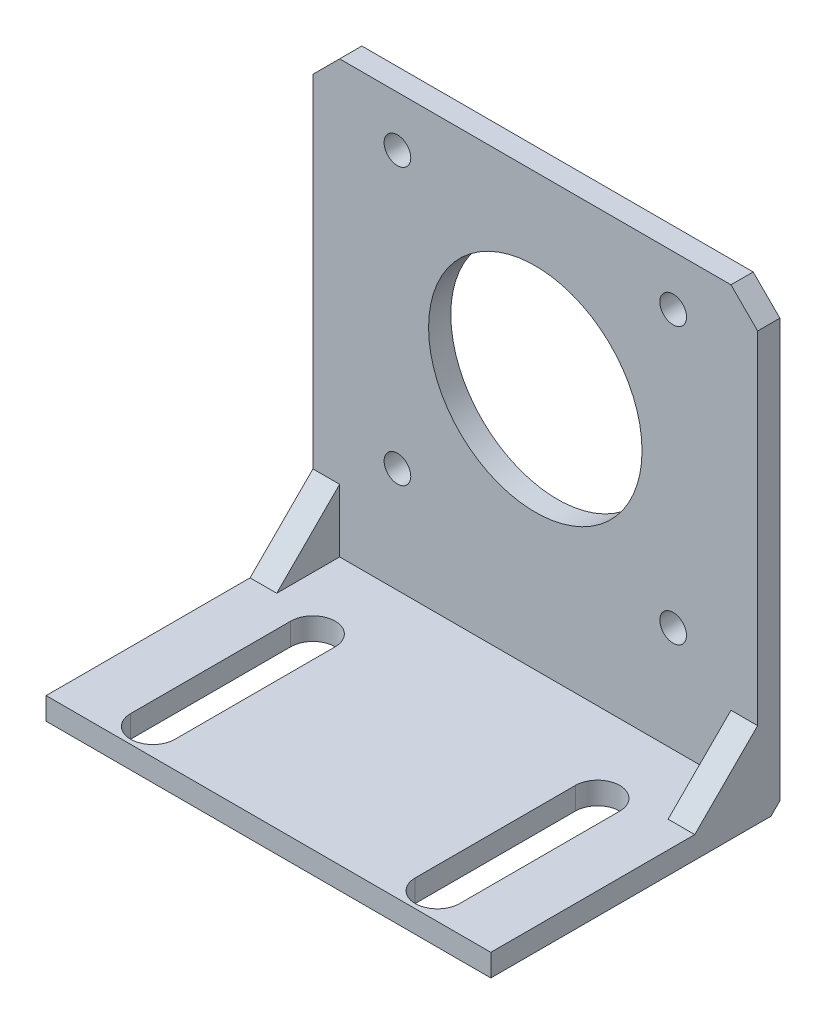
from build123d import *

# Parameters (mm, degrees)
SKETCH1_R           = 12
SKETCH1_R_2         = 1.5
BOSS_EXTRUDE1_DEPTH = 2.5
BOSS_EXTRUDE2_DEPTH = 2.5
SKETCH3_W           = 50
SKETCH3_H           = 2.5
BOSS_EXTRUDE3_DEPTH = 30
SKETCH4_W           = 5
SKETCH4_H           = 18
CUT_EXTRUDE1_DEPTH  = 3.5
BOSS_EXTRUDE4_DEPTH = 3
CHAMFER1_SIZE       = 1


with BuildPart() as part:
    # Sketch1 → Boss-Extrude1 (new body)
    with BuildSketch(Plane.XY):
        Polygon((25, 18.15), (22, 21.15), (-22, 21.15), (-25, 18.15), (-25, -23.85), (-22, -26.85), (22, -26.85), (25, -23.85), align=None)
        Circle(SKETCH1_R, mode=Mode.SUBTRACT)
        with Locations((-15.5, 15.5)):
            Circle(SKETCH1_R_2, mode=Mode.SUBTRACT)
        with Locations((15.5, 15.5)):
            Circle(SKETCH1_R_2, mode=Mode.SUBTRACT)
        with Locations((-15.5, -15.5)):
            Circle(SKETCH1_R_2, mode=Mode.SUBTRACT)
        with Locations((15.5, -15.5)):
            Circle(SKETCH1_R_2, mode=Mode.SUBTRACT)
    extrude(amount=BOSS_EXTRUDE1_DEPTH)

    # Sketch2 → Boss-Extrude2 (add)
    with BuildSketch(Plane(origin=(0, 0, 0), x_dir=(-1, 0, 0), z_dir=(0, 0, -1))):
        Polygon((-25, -23.85), (-25, -29.85), (25, -29.85), (25, -23.85), (22, -26.85), (-22, -26.85), align=None)
    extrude(amount=-BOSS_EXTRUDE2_DEPTH)

    # Sketch3 → Boss-Extrude3 (add)
    with BuildSketch(Plane.XY.offset(2.5)):
        with Locations((0, -28.6)):
            Rectangle(SKETCH3_W, SKETCH3_H)
    extrude(amount=BOSS_EXTRUDE3_DEPTH)

    # Sketch4 → Cut-Extrude1 (cut, through all)
    with BuildSketch(Plane(origin=(0, -27.35, 0), x_dir=(1, 0, 0), z_dir=(0, 1, 0))):
        with BuildLine():
            Line((13.5, -29.5), (18.5, -29.5))
            ThreePointArc((18.5, -29.5), (16, -32), (13.5, -29.5))
        make_face()
        with Locations((16, -20.5)):
            Rectangle(SKETCH4_W, SKETCH4_H)
        with BuildLine():
            Line((13.5, -11.5), (18.5, -11.5))
            ThreePointArc((18.5, -11.5), (16, -9), (13.5, -11.5))
        make_face()
        with BuildLine():
            Line((-18.5, -11.5), (-13.5, -11.5))
            ThreePointArc((-13.5, -11.5), (-16, -9), (-18.5, -11.5))
        make_face()
        with Locations((-16, -20.5)):
            Rectangle(SKETCH4_W, SKETCH4_H)
        with BuildLine():
            ThreePointArc((-13.5, -29.5), (-16, -32), (-18.5, -29.5))
            Line((-18.5, -29.5), (-13.5, -29.5))
        make_face()
    extrude(amount=-CUT_EXTRUDE1_DEPTH, mode=Mode.SUBTRACT)

    # Sketch5 → Boss-Extrude4 (add)
    with BuildSketch(Plane(origin=(25, 0, 0), x_dir=(0, 0, -1), z_dir=(1, 0, 0))):
        Polygon((-2.5, -27.35), (-2.5, -20.278932188), (-9.571067812, -27.35), align=None)
    boss_extrude4 = extrude(amount=-BOSS_EXTRUDE4_DEPTH)

    # Mirror1: Boss-Extrude4 across plane
    add(boss_extrude4.mirror(Plane(origin=(0, 0, 0), x_dir=(0, 0, 1), z_dir=(1, 0, 0))))

    # Chamfer1
    chamfer1_edges = [part.edges().sort_by_distance(p)[0] for p in [
        (0, -29.85, 0),
    ]]
    chamfer(chamfer1_edges, length=CHAMFER1_SIZE)


solid = part.part
